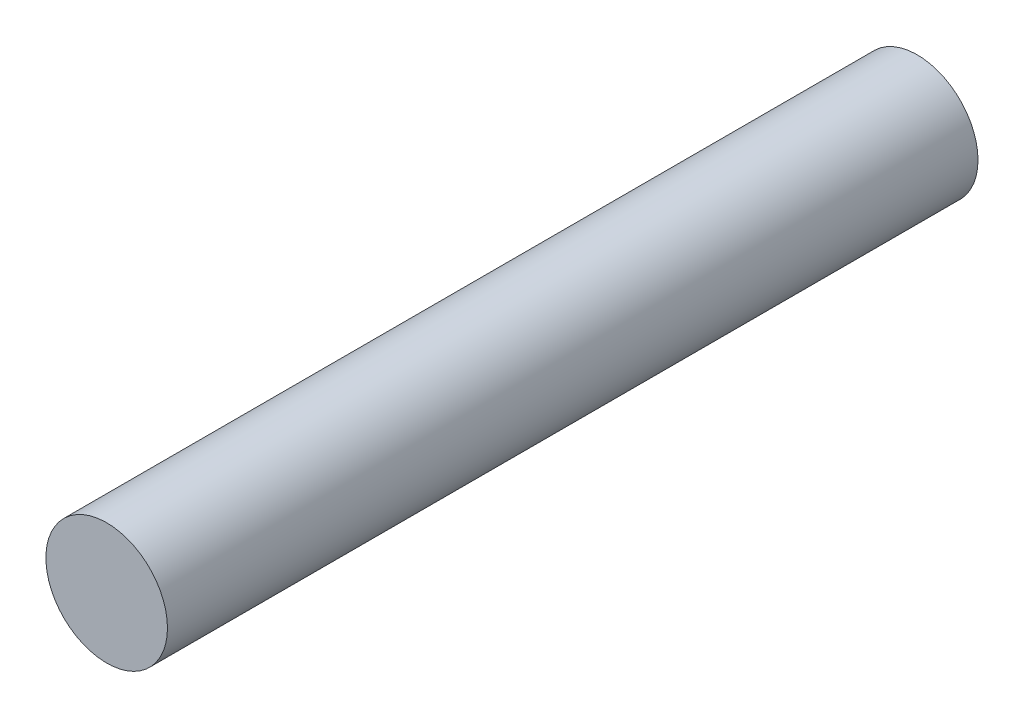
from build123d import *

# Parameters (mm, degrees)
ESQUISSE1_R        = 1.5
BOSS_EXTRU_1_DEPTH = 20


with BuildPart() as part:
    # Esquisse1 → Boss.-Extru.1 (new body)
    with BuildSketch(Plane.XY):
        Circle(ESQUISSE1_R)
    extrude(amount=BOSS_EXTRU_1_DEPTH)


solid = part.part
